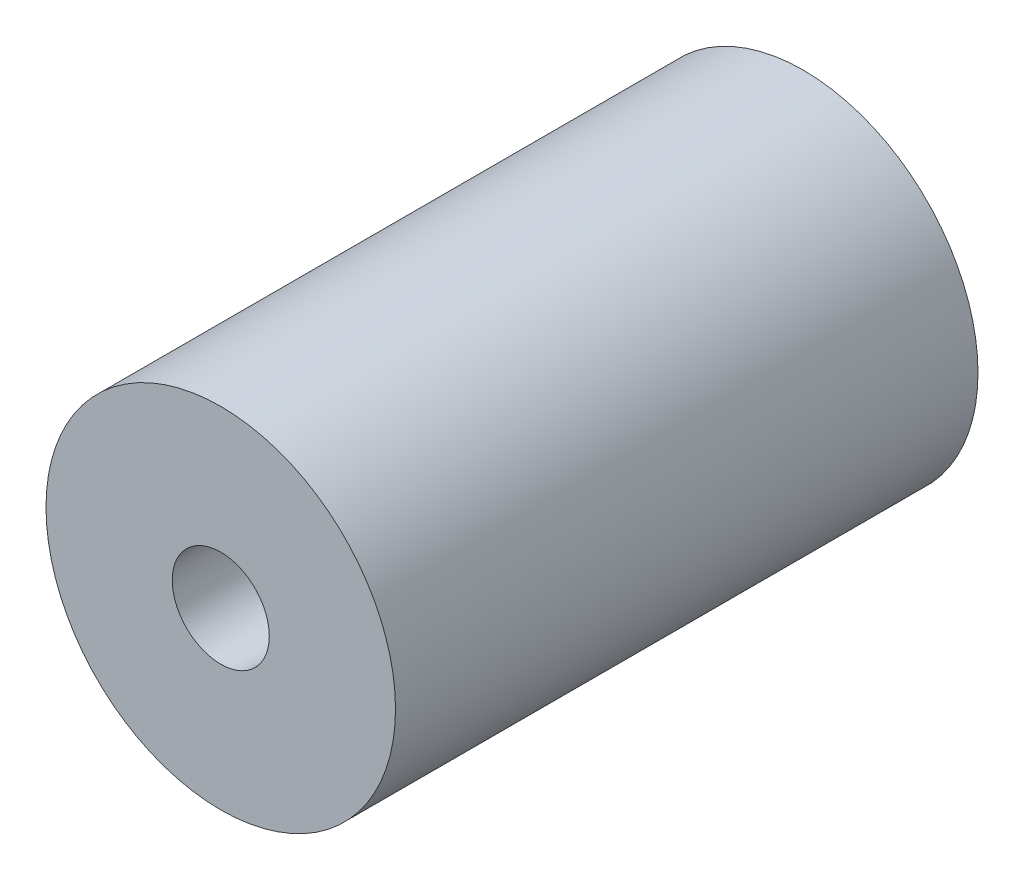
from build123d import *

# Parameters (mm, degrees)
SKETCH_1_R            = 9
EXTRUDE_1_DEPTH       = 30
HOLE_WIZARD_M61_D     = 5
HOLE_WIZARD_M61_DEPTH = 40
HOLE_WIZARD_M61_TIP   = 1.502151548


with BuildPart() as part:
    # Эскиз1 → Бобышка-Вытянуть1 (new body)
    with BuildSketch(Plane.XY):
        with Locations((10.65, -10.65)):
            Circle(SKETCH_1_R)
    extrude(amount=-EXTRUDE_1_DEPTH)

    # Отверстие обработанное метчиком M61
    with Locations(Plane.XY):
        with Locations((10.65, -10.65)):
            Hole(HOLE_WIZARD_M61_D / 2, depth=HOLE_WIZARD_M61_DEPTH)
            with Locations((0, 0, -(HOLE_WIZARD_M61_DEPTH + HOLE_WIZARD_M61_TIP / 2))):  # 118° drill point
                Cone(0, HOLE_WIZARD_M61_D / 2, HOLE_WIZARD_M61_TIP, mode=Mode.SUBTRACT)


solid = part.part
